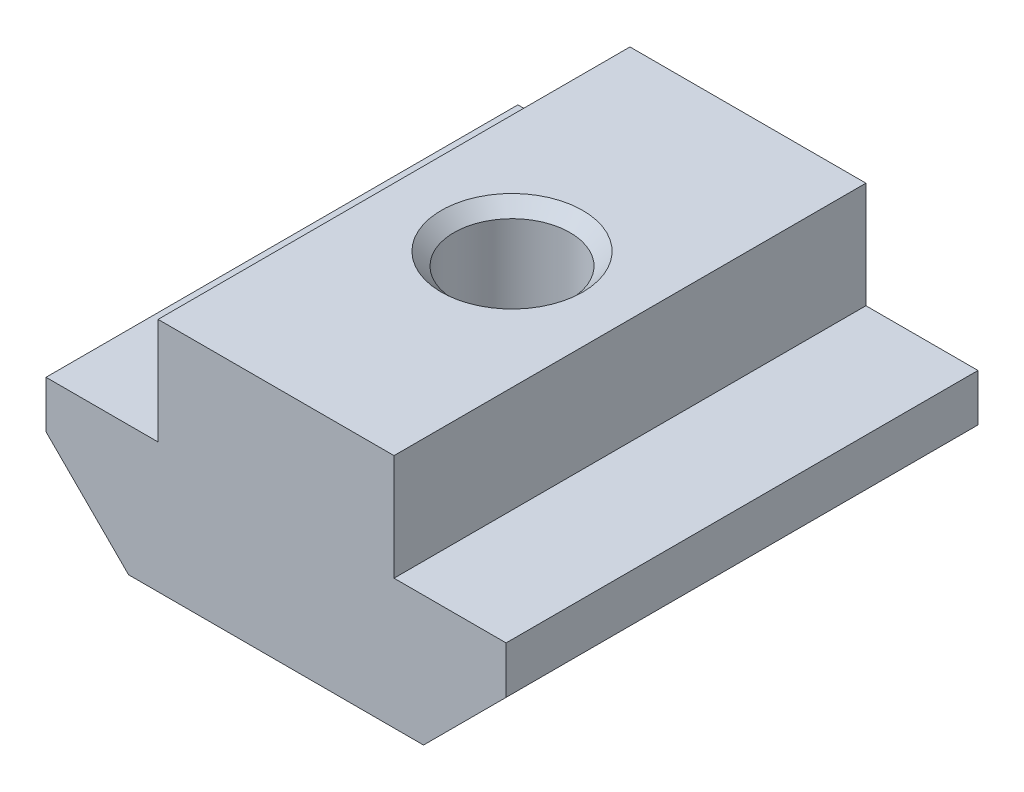
from build123d import *

# Parameters (mm, degrees)
BOSS_EXTRU_1_DEPTH      = 20
ESQUISSE2_W             = 4.75
ESQUISSE2_H             = 4.5
ENL_V_MAT_EXTRU_1_DEPTH = 21
ESQUISSE3_W             = 4.75
ESQUISSE3_H             = 4.5
ENL_V_MAT_EXTRU_2_DEPTH = 21


with BuildPart() as part:
    # Esquisse1 → Boss.-Extru.1 (new body)
    with BuildSketch(Plane(origin=(0, 0, -10), x_dir=(-1, 0, 0), z_dir=(0, 0, -1))):
        Polygon((9.75, -1.5), (9.75, 5), (-9.75, 5), (-9.75, -1.5), (-6.25, -5), (6.25, -5), align=None)
    extrude(amount=-BOSS_EXTRU_1_DEPTH)

    # Esquisse2 → Enlèv. mat.-Extru.1 (cut, through all)
    with BuildSketch(Plane(origin=(0, 0, -10), x_dir=(-1, 0, 0), z_dir=(0, 0, -1))):
        with Locations((-7.375, 2.75)):
            Rectangle(ESQUISSE2_W, ESQUISSE2_H)
    extrude(amount=-ENL_V_MAT_EXTRU_1_DEPTH, mode=Mode.SUBTRACT)

    # Esquisse3 → Enlèv. mat.-Extru.2 (cut, through all)
    with BuildSketch(Plane(origin=(0, 0, -10), x_dir=(-1, 0, 0), z_dir=(0, 0, -1))):
        with Locations((7.375, 2.75)):
            Rectangle(ESQUISSE3_W, ESQUISSE3_H)
    extrude(amount=-ENL_V_MAT_EXTRU_2_DEPTH, mode=Mode.SUBTRACT)

    # Esquisse4 → Enlèvement de matière-Révolution1 (revolve, cut)
    with BuildSketch(Plane.XY):
        Polygon((3, 5), (0, 5), (0, -5), (3, -5), (2.4585, -4.4585), (2.4585, 4.4585), align=None)
    revolve(axis=Axis((0, 5, 0), (0, -1, 0)), mode=Mode.SUBTRACT)


solid = part.part
